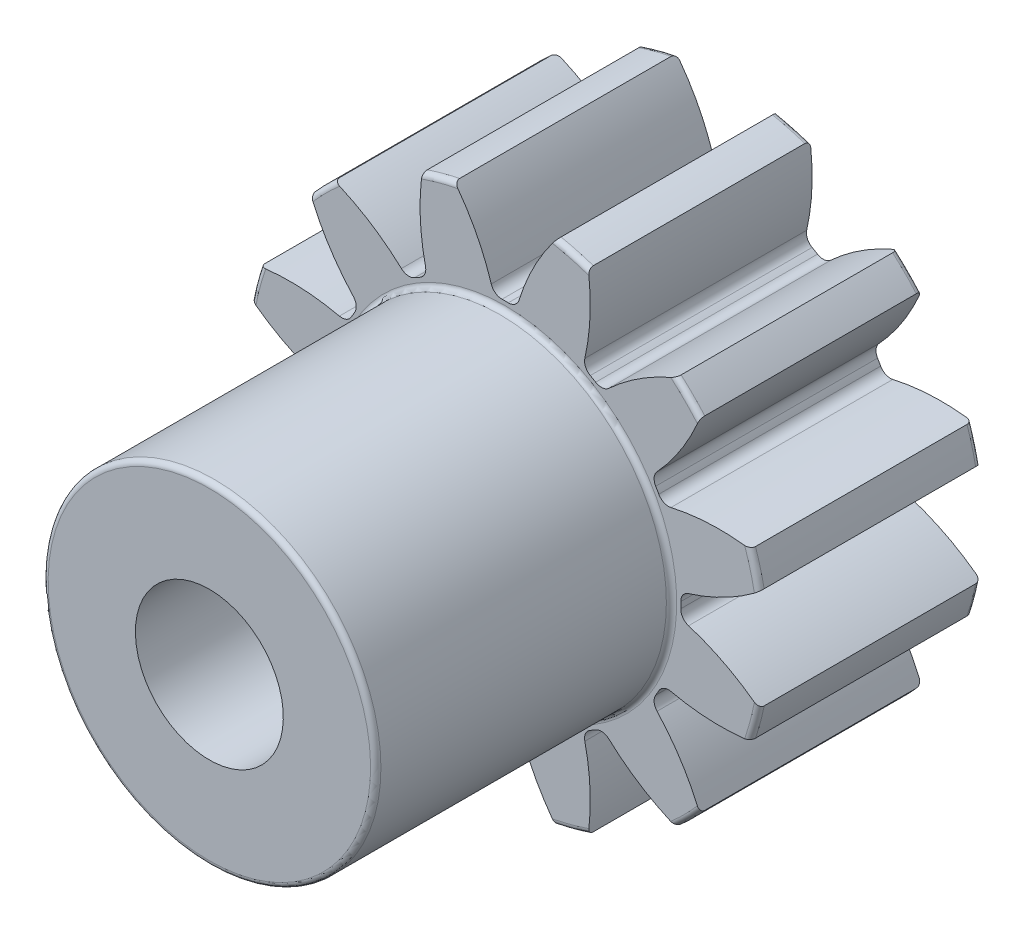
from build123d import *

# Parameters (mm, degrees)
FILLET2_R          = 0.07
CUT_EXTRUDE2_DEPTH = 4
CIRPATTERN1_COUNT  = 12


with BuildPart() as part:
    # Sketch4 → Revolve1 (revolve)
    with BuildSketch(Plane(origin=(0, 0, 0), x_dir=(0, 0, -1), z_dir=(1, 0, 0))):
        Polygon((-7, 1), (-7, 2.25), (-3, 2.25), (-3, 3.5), (0, 3.5), (0, 1), align=None)
    revolve(axis=Axis((0, 0, 3), (0, 0, 1)))

    # Fillet2
    fillet2_edges = [part.edges().sort_by_distance(p)[0] for p in [
        (0, -3.5, 0),
        (0, -3.5, 3),
        (0, -2.25, 3),
        (0, -2.25, 7),
    ]]
    fillet(fillet2_edges, radius=FILLET2_R)

    # Sketch7 → Cut-Extrude2 (cut, through all)
    with BuildSketch(Plane.XY.offset(3)):
        with BuildLine():
            ThreePointArc((-0.042070551, 2.374627354), (0, 2.375), (0.042070551, 2.374627354))
            ThreePointArc((0.042070551, 2.374627354), (0.13259254, 2.40302909), (0.187970292, 2.480062809))
            ThreePointArc((0.187970292, 2.480062809), (0.393796454, 2.978587459), (0.685558819, 3.432201787))
            ThreePointArc((0.685558819, 3.432201787), (0, 3.5), (-0.685558819, 3.432201787))
            ThreePointArc((-0.685558819, 3.432201787), (-0.393796454, 2.978587459), (-0.187970292, 2.480062809))
            ThreePointArc((-0.187970292, 2.480062809), (-0.13259254, 2.40302909), (-0.042070551, 2.374627354))
        make_face()
    cut_extrude2 = extrude(amount=-CUT_EXTRUDE2_DEPTH, mode=Mode.SUBTRACT)

    # CirPattern1: Cut-Extrude2 ×12 about axis
    cirpattern1_axis = Axis((0, 0, 0), (0, 0, 1))
    for i in range(1, CIRPATTERN1_COUNT):
        add(cut_extrude2.rotate(cirpattern1_axis, i * 360 / CIRPATTERN1_COUNT), mode=Mode.SUBTRACT)


solid = part.part
